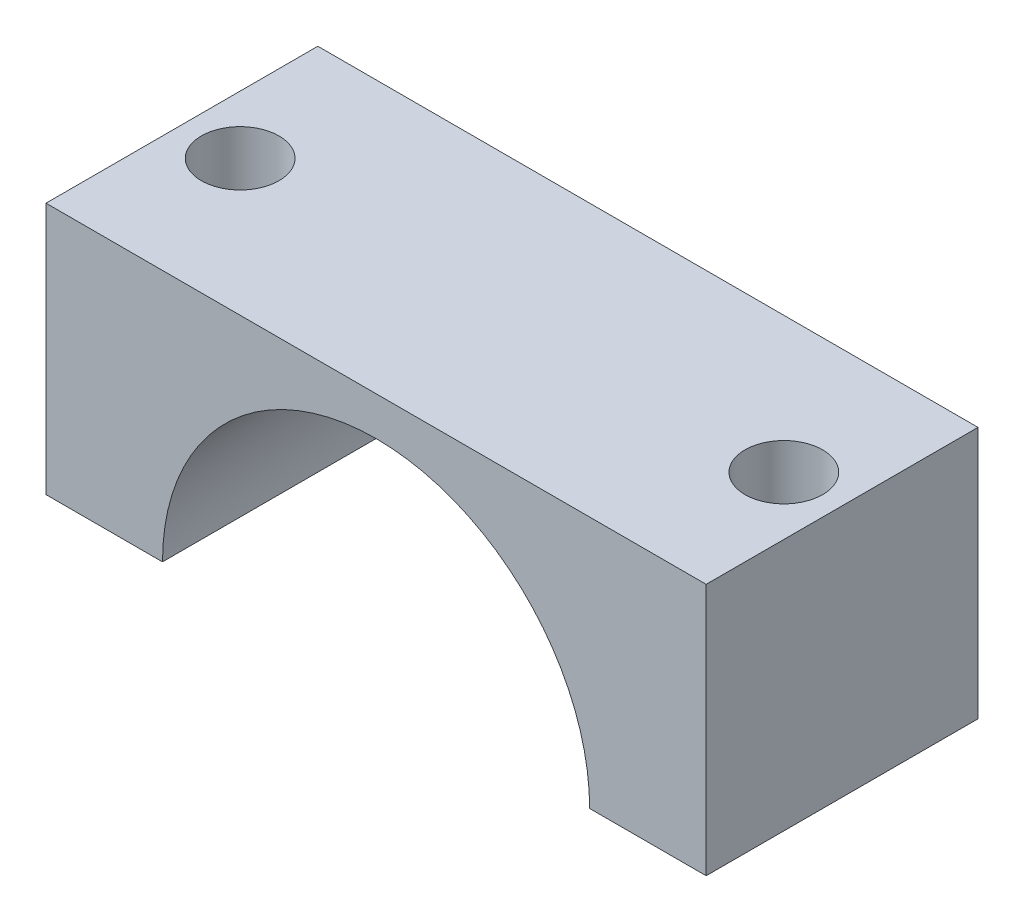
from build123d import *

# Parameters (mm, degrees)
EXTRUSION1_DEPTH = 14
ESQUISSE2_R      = 2
EXTRUSION2_DEPTH = 14


with BuildPart() as part:
    # Esquisse1 → Extrusion1 (new body)
    with BuildSketch(Plane.XY):
        with BuildLine():
            Line((-17, 0), (-17, 13))
            Line((-17, 13), (17, 13))
            Line((17, 13), (17, 0))
            Line((17, 0), (11, 0))
            ThreePointArc((11, 0), (0, 11), (-11, 0))
            Line((-11, 0), (-17, 0))
        make_face()
    extrude(amount=EXTRUSION1_DEPTH)

    # Esquisse2 → Extrusion2 (cut, through all)
    with BuildSketch(Plane(origin=(0, 13, 0), x_dir=(1, 0, 0), z_dir=(0, 1, 0))):
        with Locations((-14, -7)):
            Circle(ESQUISSE2_R)
        with Locations((14, -7)):
            Circle(ESQUISSE2_R)
    extrude(amount=-EXTRUSION2_DEPTH, mode=Mode.SUBTRACT)


solid = part.part
